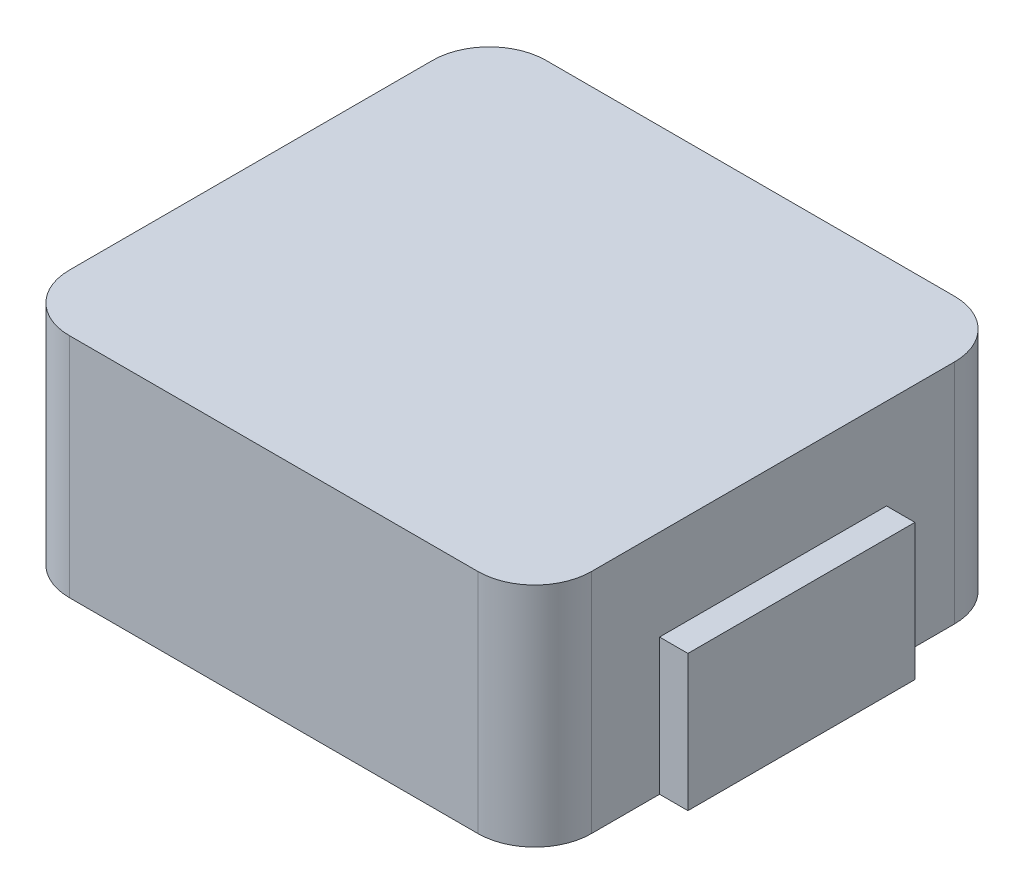
from build123d import *

# Parameters (mm, degrees)
SKETCH_1_W      = 4.6
SKETCH_1_H      = 4.2
EXTRUDE_1_DEPTH = 2
FILLET_1_R      = 0.5
SKETCH_2_W      = 0.5
SKETCH_2_H      = 2
EXTRUDE_2_DEPTH = 1.2


with BuildPart() as part:
    # 草图1 → 凸台-拉伸1 (new body)
    with BuildSketch(Plane(origin=(0, 0, 0), x_dir=(1, 0, 0), z_dir=(0, 1, 0))):
        Rectangle(SKETCH_1_W, SKETCH_1_H)
    extrude(amount=EXTRUDE_1_DEPTH)

    # 圆角1
    fillet_1_edges = [part.edges().sort_by_distance(p)[0] for p in [
        (2.3, 1, 2.1),
        (-2.3, 1, 2.1),
        (-2.3, 1, -2.1),
        (2.3, 1, -2.1),
    ]]
    fillet(fillet_1_edges, radius=FILLET_1_R)

    # 草图2 → 凸台-拉伸2 (add)
    with BuildSketch(Plane.XZ):
        with Locations((-2.3, 0)):
            Rectangle(SKETCH_2_W, SKETCH_2_H)
        with Locations((2.3, 0)):
            Rectangle(SKETCH_2_W, SKETCH_2_H)
    extrude(amount=-EXTRUDE_2_DEPTH)


solid = part.part
